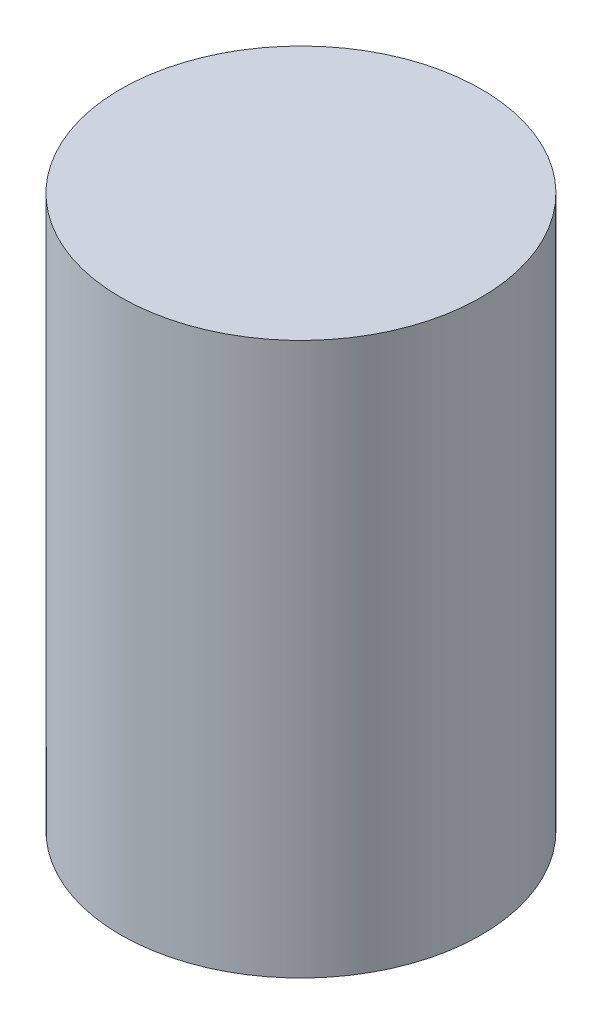
from build123d import *

# Parameters (mm, degrees)
SKETCH1_R           = 4.064
BOSS_EXTRUDE1_DEPTH = 12.446


with BuildPart() as part:
    # Sketch1 → Boss-Extrude1 (new body)
    with BuildSketch(Plane(origin=(0, 0, 0), x_dir=(1, 0, 0), z_dir=(0, 1, 0))):
        Circle(SKETCH1_R)
    extrude(amount=BOSS_EXTRUDE1_DEPTH)


solid = part.part
